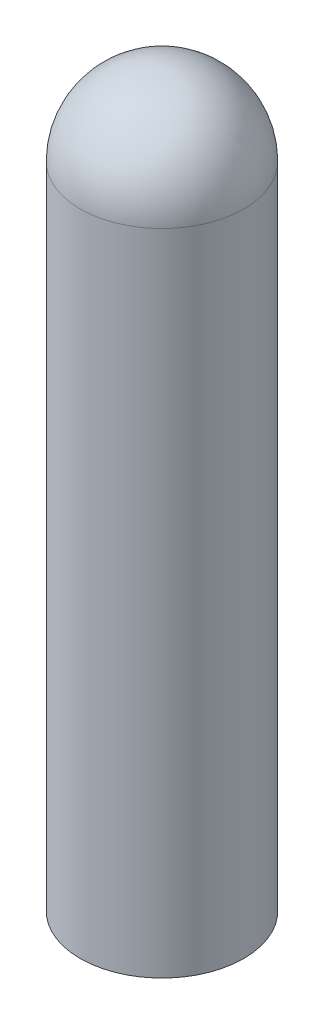
from build123d import *

# Parameters (mm, degrees)
SKETCH2_R          = 3.175
CUT_EXTRUDE1_DEPTH = 28.575


with BuildPart() as part:
    # Sketch1 → Revolve1 (revolve)
    with BuildSketch(Plane.XY):
        with BuildLine():
            Line((-3.556, 0), (-3.556, 28.194))
            ThreePointArc((-3.556, 28.194), (-2.514471714, 30.708471714), (0, 31.75))
            Line((0, 31.75), (0, 0))
            Line((0, 0), (-3.556, 0))
        make_face()
    revolve(axis=Axis((0, 0, 0), (0, -1, 0)))

    # Sketch2 → Cut-Extrude1 (cut)
    with BuildSketch(Plane.XZ):
        Circle(SKETCH2_R)
    extrude(amount=-CUT_EXTRUDE1_DEPTH, mode=Mode.SUBTRACT)


solid = part.part
